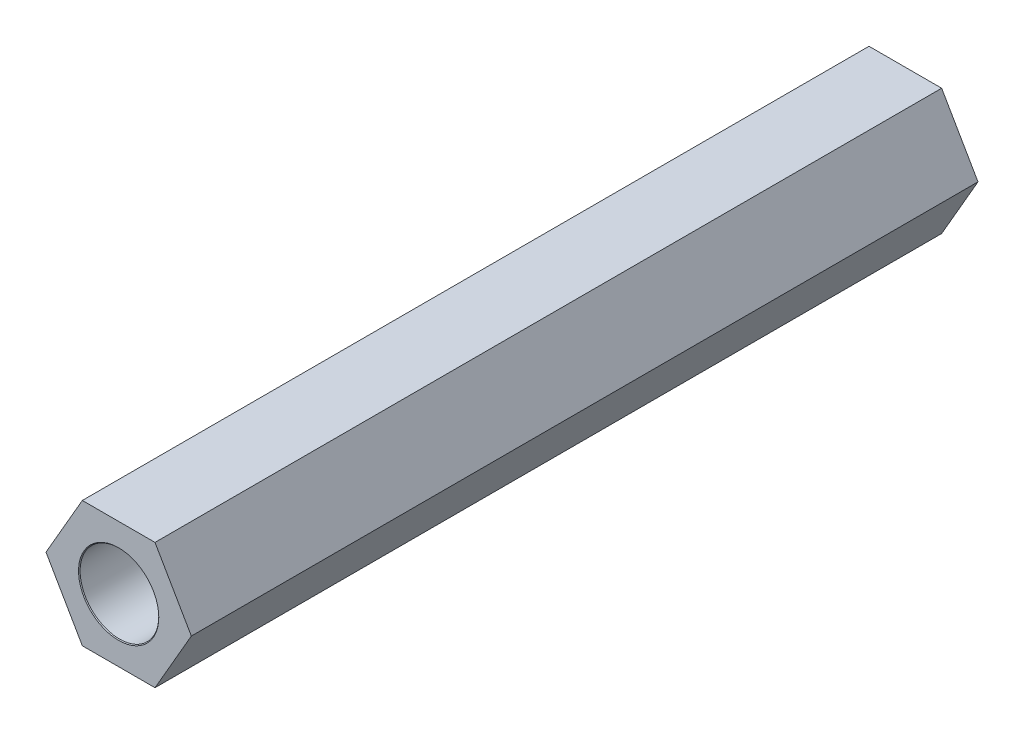
from build123d import *

# Parameters (mm, degrees)
BOSS_EXTRUDE1_DEPTH             = 25
F_2_5MM_DOWEL_HOLE2_D           = 2.5
F_2_5MM_DOWEL_HOLE2_CSINK_D     = 2.55
F_2_5MM_DOWEL_HOLE2_CSINK_ANGLE = 90


with BuildPart() as part:
    # Sketch1 → Boss-Extrude1 (new body)
    with BuildSketch(Plane.XY):
        Polygon((-83.690598923, -116.654243634), (-84.845299462, -114.654243634), (-87.154700538, -114.654243634), (-88.309401077, -116.654243634), (-87.154700538, -118.654243634), (-84.845299462, -118.654243634), align=None)
    extrude(amount=BOSS_EXTRUDE1_DEPTH)

    # Ø2.5mm Dowel Hole2 (through all)
    with Locations(Plane(origin=(-86, -116.654243634, 25), x_dir=(1, 0, 0), z_dir=(0, 0, 1))):
        with Locations((0, 0)):
            CounterSinkHole(F_2_5MM_DOWEL_HOLE2_D / 2, F_2_5MM_DOWEL_HOLE2_CSINK_D / 2, counter_sink_angle=F_2_5MM_DOWEL_HOLE2_CSINK_ANGLE)


solid = part.part
